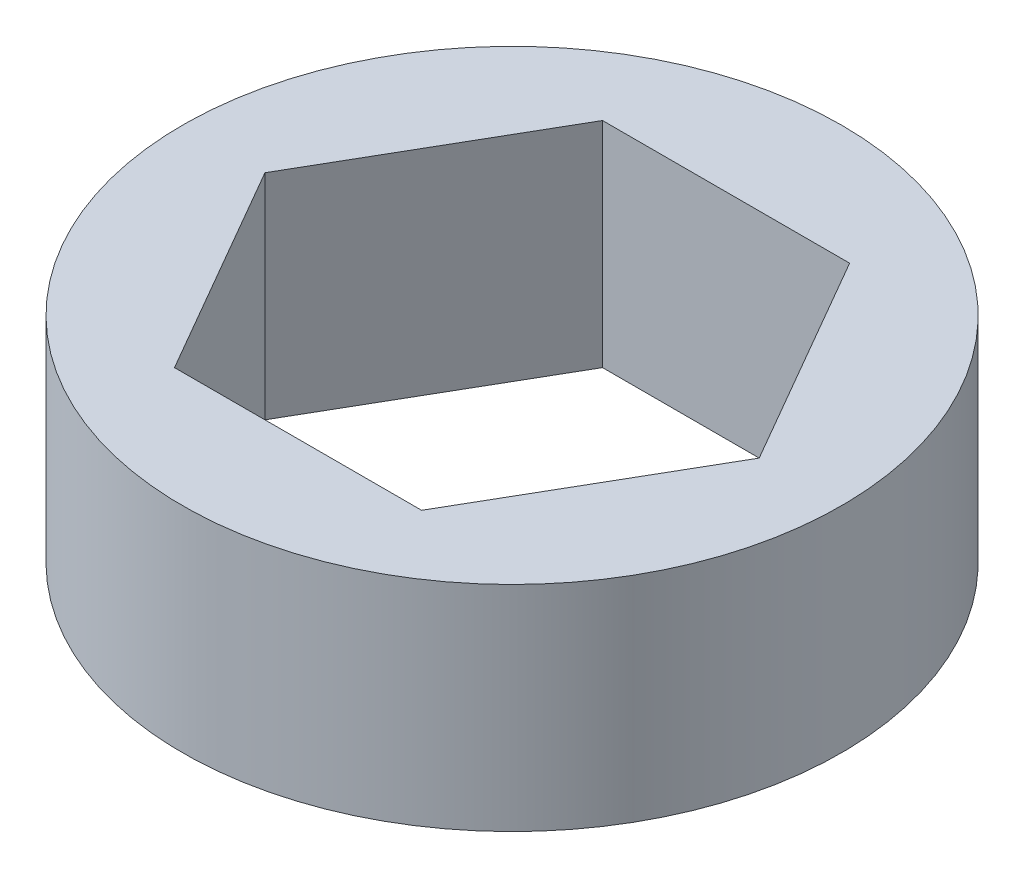
from build123d import *

# Parameters (mm, degrees)
SKETCH1_R           = 9.779
BOSS_EXTRUDE1_DEPTH = 3.175


with BuildPart() as part:
    # Sketch1 → Boss-Extrude1 (new body, symmetric)
    with BuildSketch(Plane(origin=(0, 0, 0), x_dir=(1, 0, 0), z_dir=(0, 1, 0))):
        Circle(SKETCH1_R)
        Polygon((-3.666174209, 6.35), (-7.332348419, 0), (-3.666174209, -6.35), (3.666174209, -6.35), (7.332348419, 0), (3.666174209, 6.35), align=None, mode=Mode.SUBTRACT)
    extrude(amount=BOSS_EXTRUDE1_DEPTH, both=True)


solid = part.part
